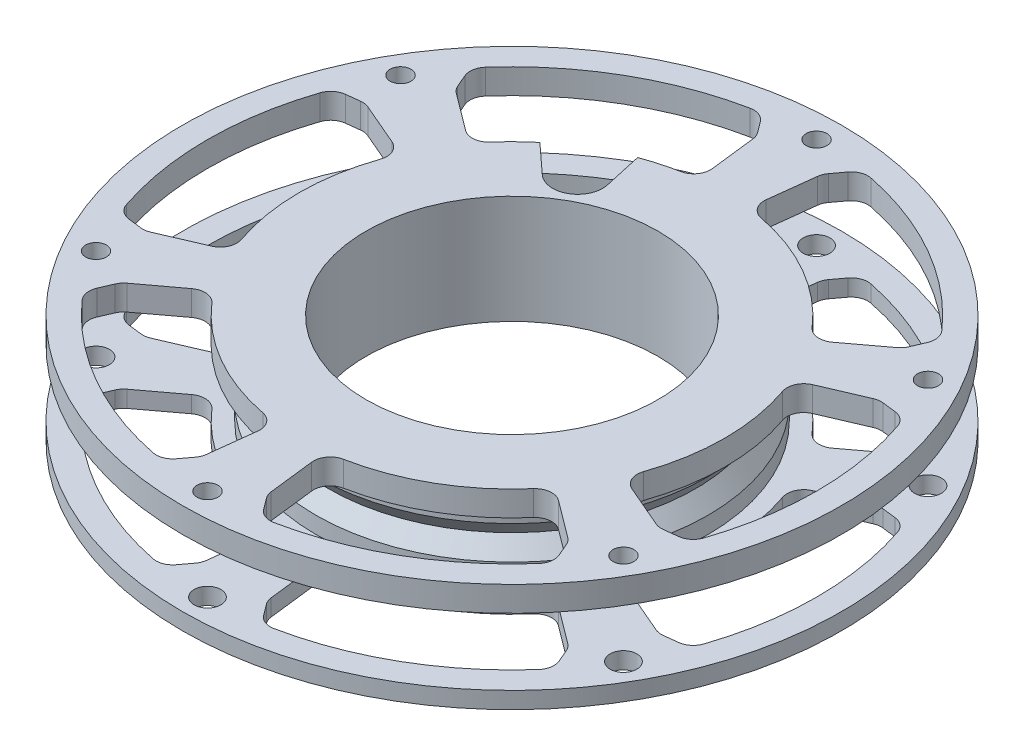
from build123d import *

# Parameters (mm, degrees)
SKETCH2_R                = 39.5
BOSS_EXTRUDE1_DEPTH      = 2
SKETCH5_R                = 17.5
CUT_EXTRUDE1_DEPTH       = 2
SKETCH18_R               = 39.5
SKETCH18_R_2             = 17.5
BOSS_EXTRUDE2_DEPTH      = 1
CUT_EXTRUDE2_START       = -3
CUT_EXTRUDE2_DEPTH       = 15
FILLET1_R                = 2
CIRPATTERN1_COUNT        = 6
FILLET1_OF_CIRPATTERN1_R = 2
M3_CLEARANCE_HOLE1_D     = 3.2
M3_CLEARANCE_HOLE1_DEPTH = 2
M3X0_5_TAPPED_HOLE2_D    = 2.5
CUT_EXTRUDE3_DEPTH       = 7.2
M3X0_5_TAPPED_HOLE1_D    = 2.5
FILLET2_R                = 0.5


with BuildPart() as part:
    # Sketch2 → Boss-Extrude1 (new body)
    with BuildSketch(Plane(origin=(0, 0, 0), x_dir=(1, 0, 0), z_dir=(0, 1, 0))):
        Circle(SKETCH2_R)
    boss_extrude1 = extrude(amount=BOSS_EXTRUDE1_DEPTH)

    # Sketch5 → Cut-Extrude1 (cut)
    with BuildSketch(Plane(origin=(0, 2, 0), x_dir=(1, 0, 0), z_dir=(0, 1, 0))):
        Circle(SKETCH5_R)
    cut_extrude1 = extrude(amount=-CUT_EXTRUDE1_DEPTH, mode=Mode.SUBTRACT)

    # Sketch7 → Revolve1 (revolve)
    with BuildSketch(Plane(origin=(0, 0, 0), x_dir=(0, 0, -1), z_dir=(1, 0, 0))):
        Polygon((17.5, 2), (17.5, 10), (23.5, 10), (23.5, 8), (22, 6), (23.5, 4), (23.5, 2), align=None)
    revolve(axis=Axis((0, 0, 0), (0, 1, 0)))

    # Mirror3: Boss-Extrude1, Cut-Extrude1 across plane
    add(boss_extrude1.mirror(Plane.ZX.offset(6)))
    add(cut_extrude1.mirror(Plane.ZX.offset(6)), mode=Mode.SUBTRACT)

    # Sketch18 → Boss-Extrude2 (add)
    with BuildSketch(Plane(origin=(0, 12, 0), x_dir=(1, 0, 0), z_dir=(0, 1, 0))):
        Circle(SKETCH18_R)
        Circle(SKETCH18_R_2, mode=Mode.SUBTRACT)
    extrude(amount=BOSS_EXTRUDE2_DEPTH)

    # Sketch9 → Cut-Extrude2 (cut)
    with BuildSketch(Plane(origin=(0, 2, 0), x_dir=(1, 0, 0), z_dir=(0, 1, 0)).offset(CUT_EXTRUDE2_START)):
        with BuildLine():
            Line((-23.430287276, -10.063381051), (-30.780965637, -13.220520204))
            Line((-30.780965637, -13.220520204), (-34.175110769, -12.818416592))
            ThreePointArc((-34.175110769, -12.818416592), (-36.5, 0), (-34.175110769, 12.818416592))
            Line((-34.175110769, 12.818416592), (-30.780965637, 13.220520204))
            Line((-30.780965637, 13.220520204), (-23.430287276, 10.063381051))
            ThreePointArc((-23.430287276, 10.063381051), (-25.5, 0), (-23.430287276, -10.063381051))
        make_face()
    cut_extrude2 = extrude(amount=CUT_EXTRUDE2_DEPTH, mode=Mode.SUBTRACT)

    # Fillet1
    fillet1_edges = [part.edges().sort_by_distance(p)[0] for p in [
        (-34.175110769, 1, 12.818416592),
        (-34.175110769, 1, -12.818416592),
        (-30.780965637, 1, -13.220520204),
        (-23.430287276, 1, -10.063381051),
        (-23.430287276, 1, 10.063381051),
        (-30.780965637, 1, 13.220520204),
        (-34.175110769, 11.5, 12.818416592),
        (-34.175110769, 11.5, -12.818416592),
        (-30.780965637, 11.5, -13.220520204),
        (-23.430287276, 11.5, -10.063381051),
        (-23.430287276, 11.5, 10.063381051),
        (-30.780965637, 11.5, 13.220520204),
    ]]
    fillet(fillet1_edges, radius=FILLET1_R)

    # CirPattern1: Cut-Extrude2 ×6 about axis
    cirpattern1_axis = Axis((0, 0, 0), (0, 1, 0))
    for i in range(1, CIRPATTERN1_COUNT):
        add(cut_extrude2.rotate(cirpattern1_axis, i * 360 / CIRPATTERN1_COUNT), mode=Mode.SUBTRACT)

    # Fillet1 of CirPattern1
    fillet1_of_cirpattern1_edges = [part.edges().sort_by_distance(p)[0] for p in [
        (-5.98648098, 1, 36.005722399),
        (-28.188629789, 1, 23.187305807),
        (-26.839789166, 1, 20.046838093),
        (-20.430287276, 1, 15.259533473),
        (-3, 1, 25.322914524),
        (-3.941176471, 1, 33.267358296),
        (-5.98648098, 11.5, 36.005722399),
        (-28.188629789, 11.5, 23.187305807),
        (-26.839789166, 11.5, 20.046838093),
        (-20.430287276, 11.5, 15.259533473),
        (-3, 11.5, 25.322914524),
        (-3.941176471, 11.5, 33.267358296),
        (28.188629789, 1, 23.187305807),
        (5.98648098, 1, 36.005722399),
        (3.941176471, 1, 33.267358296),
        (3, 1, 25.322914524),
        (20.430287276, 1, 15.259533473),
        (26.839789166, 1, 20.046838093),
        (28.188629789, 11.5, 23.187305807),
        (5.98648098, 11.5, 36.005722399),
        (3.941176471, 11.5, 33.267358296),
        (3, 11.5, 25.322914524),
        (20.430287276, 11.5, 15.259533473),
        (26.839789166, 11.5, 20.046838093),
        (34.175110769, 1, -12.818416592),
        (34.175110769, 1, 12.818416592),
        (30.780965637, 1, 13.220520204),
        (23.430287276, 1, 10.063381051),
        (23.430287276, 1, -10.063381051),
        (30.780965637, 1, -13.220520204),
        (34.175110769, 11.5, -12.818416592),
        (34.175110769, 11.5, 12.818416592),
        (30.780965637, 11.5, 13.220520204),
        (23.430287276, 11.5, 10.063381051),
        (23.430287276, 11.5, -10.063381051),
        (30.780965637, 11.5, -13.220520204),
        (5.98648098, 1, -36.005722399),
        (28.188629789, 1, -23.187305807),
        (26.839789166, 1, -20.046838093),
        (20.430287276, 1, -15.259533473),
        (3, 1, -25.322914524),
        (3.941176471, 1, -33.267358296),
        (5.98648098, 11.5, -36.005722399),
        (28.188629789, 11.5, -23.187305807),
        (26.839789166, 11.5, -20.046838093),
        (20.430287276, 11.5, -15.259533473),
        (3, 11.5, -25.322914524),
        (3.941176471, 11.5, -33.267358296),
        (-28.188629789, 1, -23.187305807),
        (-5.98648098, 1, -36.005722399),
        (-3.941176471, 1, -33.267358296),
        (-3, 1, -25.322914524),
        (-20.430287276, 1, -15.259533473),
        (-26.839789166, 1, -20.046838093),
        (-28.188629789, 11.5, -23.187305807),
        (-5.98648098, 11.5, -36.005722399),
        (-3.941176471, 11.5, -33.267358296),
        (-3, 11.5, -25.322914524),
        (-20.430287276, 11.5, -15.259533473),
        (-26.839789166, 11.5, -20.046838093),
    ]]
    fillet(fillet1_of_cirpattern1_edges, radius=FILLET1_OF_CIRPATTERN1_R)

    # M3 Clearance Hole1
    with Locations(Plane(origin=(0, 2, 0), x_dir=(1, 0, 0), z_dir=(0, 1, 0))):
        with Locations((0, 36.5), (-31.609927238, 18.25), (-31.609927238, -18.25), (0, -36.5), (31.609927238, -18.25), (31.609927238, 18.25)):
            Hole(M3_CLEARANCE_HOLE1_D / 2, depth=M3_CLEARANCE_HOLE1_DEPTH)

    # M3x0.5 Tapped Hole2 (through all)
    with Locations(Plane(origin=(0, 13, 0), x_dir=(1, 0, 0), z_dir=(0, 1, 0))):
        with Locations((31.609927238, -18.25), (0, -36.5), (-31.609927238, -18.25), (-31.609927238, 18.25), (0, 36.5), (31.609927238, 18.25)):
            Hole(M3X0_5_TAPPED_HOLE2_D / 2)

    # Sketch11 → Cut-Extrude3 (cut)
    with BuildSketch(Plane(origin=(0, 13, 0), x_dir=(1, 0, 0), z_dir=(0, 1, 0))):
        with BuildLine():
            Line((-12.778406746, 16.409214516), (-14.793995706, 18.25890717))
            Line((-14.793995706, 18.25890717), (-18.243367229, 21.424372596))
            Line((-18.243367229, 21.424372596), (-9.471924455, 26.689213753))
            Line((-9.471924455, 26.689213753), (-8.415679601, 21.94142969))
            Line((-8.415679601, 21.94142969), (-7.821593254, 19.27103212))
            ThreePointArc((-7.821593254, 19.27103212), (-9.25, 16.02146997), (-12.778406746, 16.409214516))
        make_face()
    extrude(amount=-CUT_EXTRUDE3_DEPTH, mode=Mode.SUBTRACT)

    # M3x0.5 Tapped Hole1 (through all)
    with Locations(Plane(origin=(0, 5.8, 0), x_dir=(1, 0, 0), z_dir=(0, 1, 0))):
        with Locations((-10.75, 18.619546181)):
            Hole(M3X0_5_TAPPED_HOLE1_D / 2)

    # Fillet2
    fillet2_edges = [part.edges().sort_by_distance(p)[0] for p in [
        (-14.235077603, 6.99985807, -17.745991724),
        (-8.250940847, 6.99985807, -21.200934691),
    ]]
    fillet(fillet2_edges, radius=FILLET2_R)


solid = part.part
